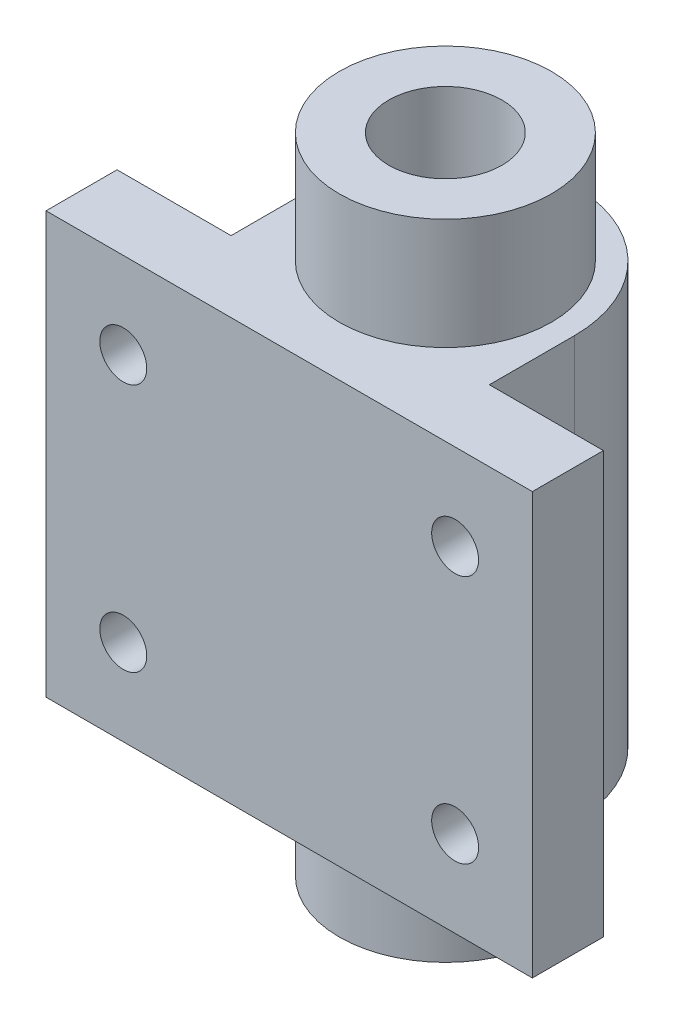
from build123d import *

# Parameters (mm, degrees)
SKETCH1_R           = 4
BOSS_EXTRUDE1_DEPTH = 29.78
SKETCH2_R           = 7.5
SKETCH2_R_2         = 4
BOSS_EXTRUDE2_DEPTH = 7.86
SKETCH3_R           = 7.5
SKETCH3_R_2         = 4
BOSS_EXTRUDE3_DEPTH = 7.86
SKETCH4_R           = 1.66
CUT_EXTRUDE1_DEPTH  = 21.17


with BuildPart() as part:
    # Sketch1 → Boss-Extrude1 (new body)
    with BuildSketch(Plane(origin=(0, 0, 0), x_dir=(1, 0, 0), z_dir=(0, 1, 0))):
        with BuildLine():
            Line((0, 0), (17.19, 0))
            Line((17.19, 0), (17.19, 5.02))
            Line((17.19, 5.02), (9.13, 5.02))
            Line((9.13, 5.02), (9.13, 11.04))
            ThreePointArc((9.13, 11.04), (0, 20.17), (-9.13, 11.04))
            Line((-9.13, 11.04), (-9.13, 5.02))
            Line((-9.13, 5.02), (-17.19, 5.02))
            Line((-17.19, 5.02), (-17.19, 0))
            Line((-17.19, 0), (0, 0))
        make_face()
        with Locations((0, 11.04)):
            Circle(SKETCH1_R, mode=Mode.SUBTRACT)
    extrude(amount=BOSS_EXTRUDE1_DEPTH)

    # Sketch2 → Boss-Extrude2 (add)
    with BuildSketch(Plane(origin=(0, 29.78, 0), x_dir=(1, 0, 0), z_dir=(0, 1, 0))):
        with Locations((0, 11.04)):
            Circle(SKETCH2_R)
        with Locations((0, 11.04)):
            Circle(SKETCH2_R_2, mode=Mode.SUBTRACT)
    extrude(amount=BOSS_EXTRUDE2_DEPTH)

    # Sketch3 → Boss-Extrude3 (add)
    with BuildSketch(Plane.XZ):
        with Locations((0, -11.04)):
            Circle(SKETCH3_R)
        with Locations((0, -11.04)):
            Circle(SKETCH3_R_2, mode=Mode.SUBTRACT)
    extrude(amount=BOSS_EXTRUDE3_DEPTH)

    # Sketch4 → Cut-Extrude1 (cut, through all)
    with BuildSketch(Plane.XY):
        with Locations((-11.73, 23.69)):
            Circle(SKETCH4_R)
        with Locations((11.73, 23.69)):
            Circle(SKETCH4_R)
        with Locations((11.73, 6.09)):
            Circle(SKETCH4_R)
        with Locations((-11.73, 6.09)):
            Circle(SKETCH4_R)
    extrude(amount=-CUT_EXTRUDE1_DEPTH, mode=Mode.SUBTRACT)


solid = part.part
